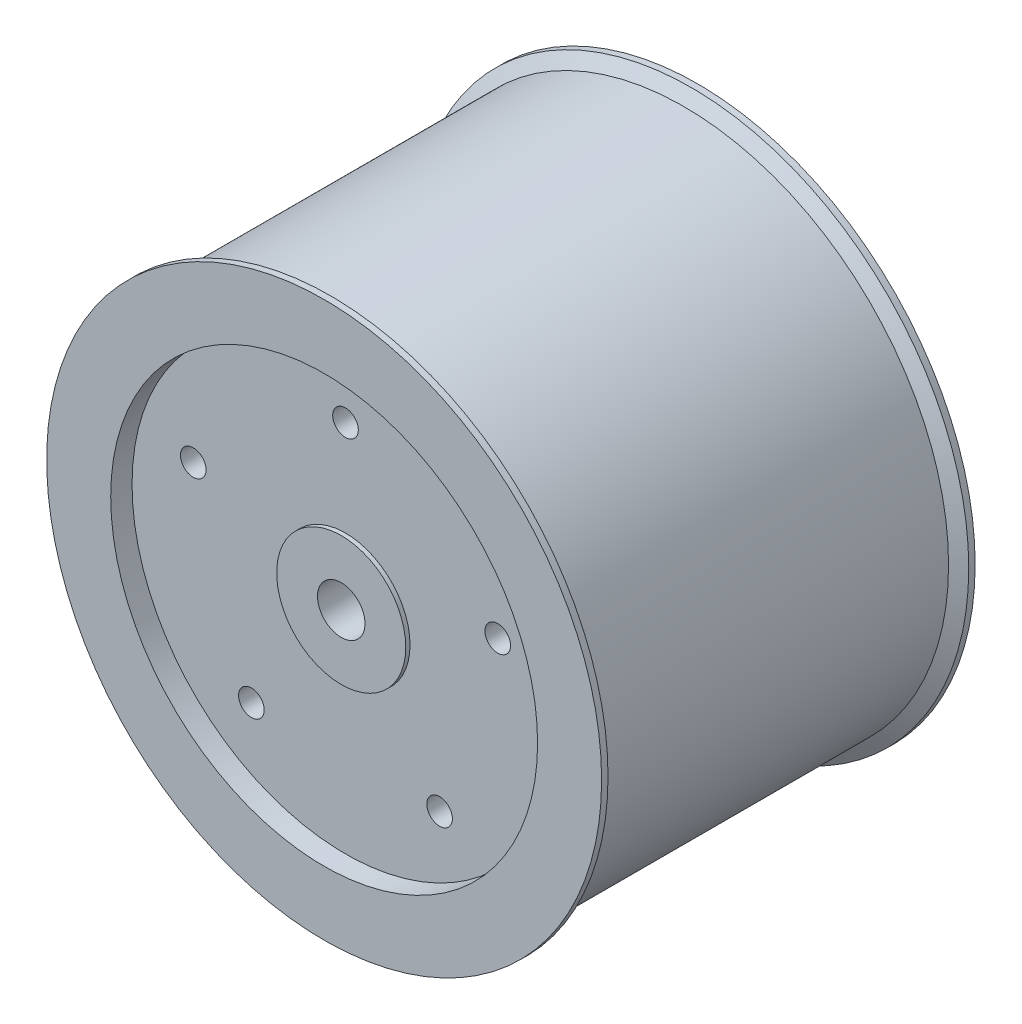
from build123d import *

# Parameters (mm, degrees)
SKETCH1_R                = 130
SKETCH1_R_2              = 11.1125
BOSS_EXTRUDE1_DEPTH      = 87.5
SKETCH2_R                = 100
CUT_EXTRUDE1_DEPTH       = 10
CUT_EXTRUDE2_START       = -166
SKETCH3_R                = 6
CUT_EXTRUDE2_DEPTH       = 177
CIRPATTERN1_COUNT        = 5
SKETCH4_R                = 30.2387
SKETCH4_R_2              = 11.1125
BOSS_EXTRUDE2_DEPTH      = 2
BOSS_EXTRUDE2_DEPTH_BACK = 7


with BuildPart() as part:
    # Sketch1 → Boss-Extrude1 (new body, symmetric)
    with BuildSketch(Plane.XY):
        Circle(SKETCH1_R)
        Circle(SKETCH1_R_2, mode=Mode.SUBTRACT)
    extrude(amount=BOSS_EXTRUDE1_DEPTH, both=True)

    # Sketch2 → Cut-Extrude1 (cut)
    with BuildSketch(Plane.XY.offset(87.5)):
        Circle(SKETCH2_R)
    cut_extrude1 = extrude(amount=-CUT_EXTRUDE1_DEPTH, mode=Mode.SUBTRACT)

    # Mirror1: Cut-Extrude1 across plane
    add(cut_extrude1.mirror(Plane.XY), mode=Mode.SUBTRACT)

    # Sketch3 → Cut-Extrude2 (cut)
    with BuildSketch(Plane.XY.offset(77.5).offset(CUT_EXTRUDE2_START)):
        with Locations((0, 75)):
            Circle(SKETCH3_R)
    cut_extrude2 = extrude(amount=CUT_EXTRUDE2_DEPTH, mode=Mode.SUBTRACT)

    # CirPattern1: Cut-Extrude2 ×5 about axis
    cirpattern1_axis = Axis((0, 0, 0), (0, 0, 1))
    for i in range(1, CIRPATTERN1_COUNT):
        add(cut_extrude2.rotate(cirpattern1_axis, i * 360 / CIRPATTERN1_COUNT), mode=Mode.SUBTRACT)

    # Sketch4 → Boss-Extrude2 (add, two sides)
    with BuildSketch(Plane.XY.offset(77.5)) as boss_extrude2_sk:
        Circle(SKETCH4_R)
        Circle(SKETCH4_R_2, mode=Mode.SUBTRACT)
    extrude(amount=BOSS_EXTRUDE2_DEPTH)
    extrude(boss_extrude2_sk.sketch, amount=-BOSS_EXTRUDE2_DEPTH_BACK)

    # Sketch5 → Cut-Revolve1 (revolve, cut)
    with BuildSketch(Plane(origin=(0, 0, 0), x_dir=(1, 0, 0), z_dir=(0, 1, 0))):
        Polygon((130, 84.5), (124, 81.035898385), (124, -81.035898385), (130, -84.5), align=None)
    revolve(axis=Axis((0, 0, 0), (0, 0, -1)), mode=Mode.SUBTRACT)


solid = part.part
